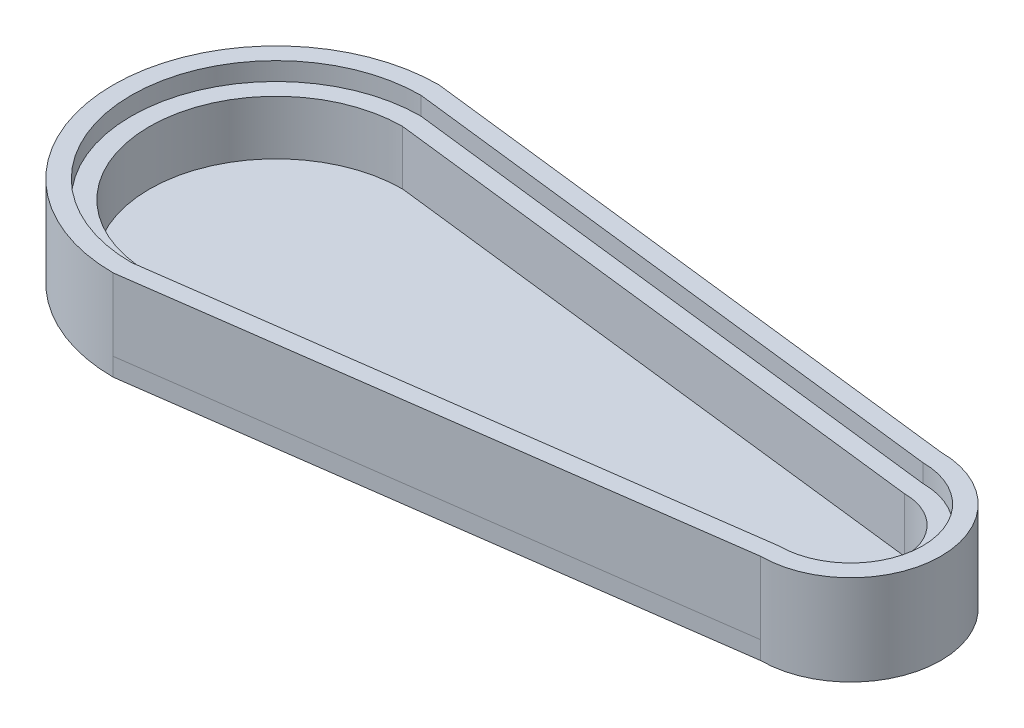
from build123d import *

# Parameters (mm, degrees)
BOSS_EXTRUDE1_DEPTH = 6.35
BOSS_EXTRUDE3_DEPTH = 25.4
CUT_EXTRUDE2_DEPTH  = 6.35


with BuildPart() as part:
    # Sketch1 → Boss-Extrude1 (new body)
    with BuildSketch(Plane(origin=(0, 0, 0), x_dir=(1, 0, 0), z_dir=(0, 1, 0))):
        with BuildLine():
            Line((0.000313665, 57.24265935), (199.999794406, 33.65314008))
            ThreePointArc((199.999794406, 33.65314008), (231.692215245, 1.96024222), (199.999317386, -29.732178619))
            Line((199.999317386, -29.732178619), (-0.001522287, -57.242659331))
            ThreePointArc((-0.001522287, -57.242659331), (-57.242659343, 0.000917976), (0.000313665, 57.24265935))
        make_face()
    extrude(amount=BOSS_EXTRUDE1_DEPTH)

    # Sketch5 → Boss-Extrude3 (add)
    with BuildSketch(Plane(origin=(0, 6.35, 0), x_dir=(1, 0, 0), z_dir=(0, 1, 0))):
        with BuildLine():
            Line((0.000313665, 57.24265935), (199.999794406, 33.65314008))
            ThreePointArc((199.999794406, 33.65314008), (231.692215246, 1.960361475), (199.999555896, -29.73217862))
            Line((199.999555896, -29.73217862), (-0.001522287, -57.242659331))
            ThreePointArc((-0.001522287, -57.242659331), (-57.242659343, 0.000917976), (0.000313665, 57.24265935))
        make_face()
        with BuildLine():
            Line((-0.10621345, 44.55), (199.893342446, 20.95048073))
            ThreePointArc((199.893342446, 20.95048073), (218.989852926, 1.96048073), (199.893342446, -17.02951927))
            Line((199.893342446, -17.02951927), (-0.10621345, -44.55))
            ThreePointArc((-0.10621345, -44.55), (-44.550126614, 0), (-0.10621345, 44.55))
        make_face(mode=Mode.SUBTRACT)
    extrude(amount=BOSS_EXTRUDE3_DEPTH)

    # Sketch6 → Cut-Extrude2 (cut)
    with BuildSketch(Plane(origin=(0, 31.75, 0), x_dir=(1, 0, 0), z_dir=(0, 1, 0))):
        with BuildLine():
            Line((0, 50.9), (199.999555896, 27.30048073))
            ThreePointArc((199.999555896, 27.30048073), (225.339555896, 1.96048073), (199.999555896, -23.37951927))
            Line((199.999555896, -23.37951927), (0, -50.9))
            ThreePointArc((0, -50.9), (-50.9, 0), (0, 50.9))
        make_face()
    extrude(amount=-CUT_EXTRUDE2_DEPTH, mode=Mode.SUBTRACT)


solid = part.part
